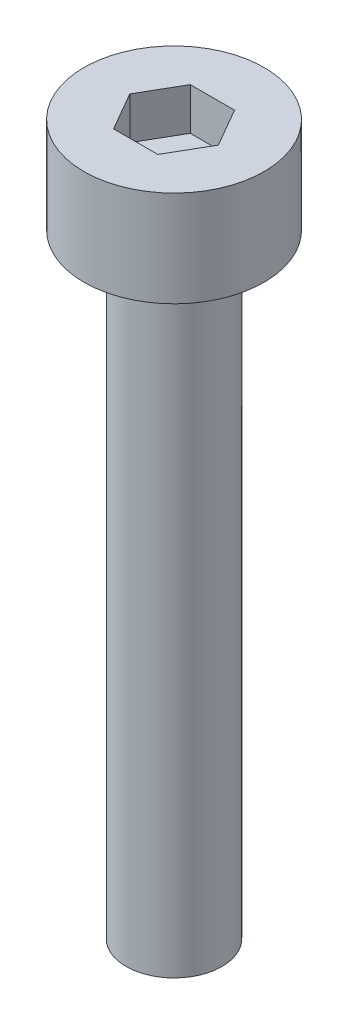
from build123d import *

# Parameters (mm, degrees)
SKETCH_1_R            = 2.35
EXTRUDE_248_DEPTH     = 2.5
CUT_EXTRUDE_382_DEPTH = 1.1
SKETCH_3_R            = 1.25
EXTRUDE_487_DEPTH     = 16


with BuildPart() as part:
    # 草图1 → Extrude 248 (new body)
    with BuildSketch(Plane(origin=(0, 0, 0), x_dir=(1, 0, 0), z_dir=(0, 1, 0))):
        Circle(SKETCH_1_R)
    extrude(amount=EXTRUDE_248_DEPTH)

    # 草图2 → Cut-Extrude 382 (cut)
    with BuildSketch(Plane(origin=(0, 2.5, 0), x_dir=(1, 0, 0), z_dir=(0, 1, 0))):
        Polygon((1.154700538, 0), (0.577350269, 1), (-0.577350269, 1), (-1.154700538, 0), (-0.577350269, -1), (0.577350269, -1), align=None)
    extrude(amount=-CUT_EXTRUDE_382_DEPTH, mode=Mode.SUBTRACT)

    # 草图3 → Extrude 487 (add)
    with BuildSketch(Plane.XZ):
        Circle(SKETCH_3_R)
    extrude(amount=EXTRUDE_487_DEPTH)


solid = part.part
